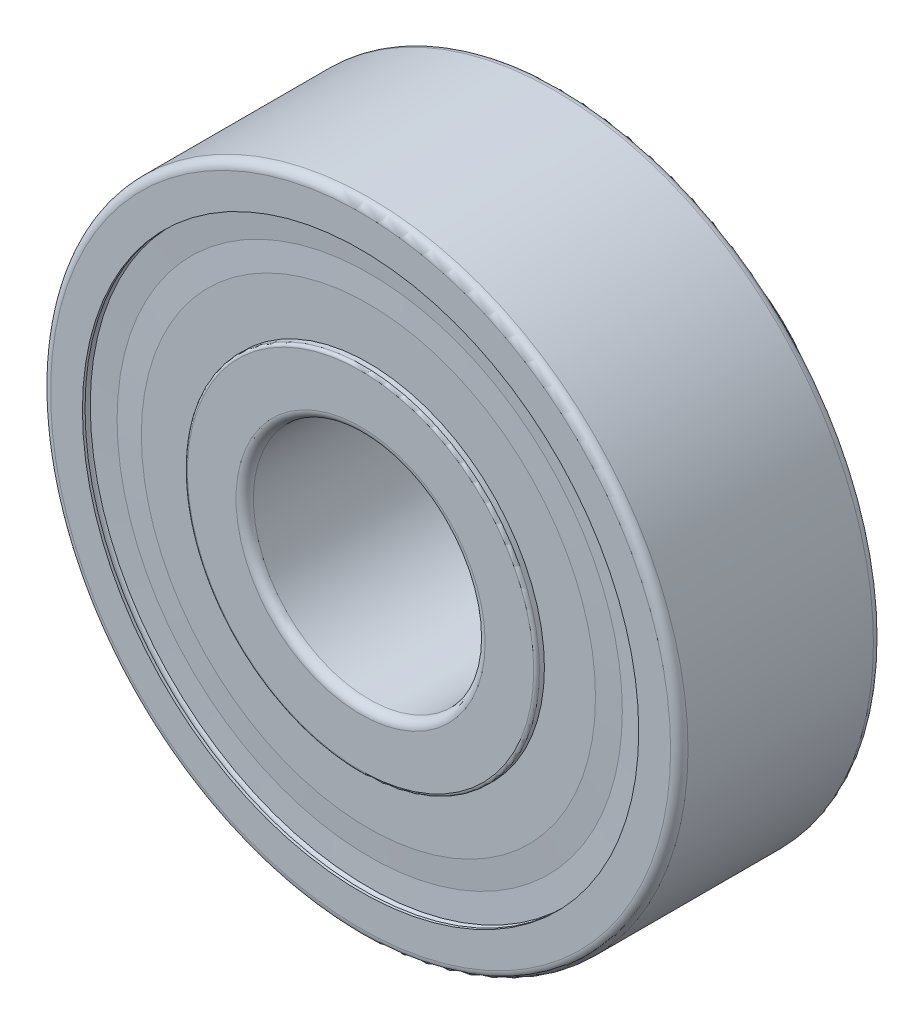
from build123d import *

# Parameters (mm, degrees)
BALL_PATTERN_COUNT              = 7
M3_SET_SCREW_HOLE_PATTERN_COUNT = 2
M3_SET_SCREW_HOLE_PATTERN_ANGLE = 90


with BuildPart() as part:
    # Sketch1 → Bearing Body (revolve)
    with BuildSketch(Plane(origin=(0, 0, 0), x_dir=(0, 0, -1), z_dir=(1, 0, 0))):
        with BuildLine():
            Line((-3.2, 4), (3.2, 4))
            Line((3.2, 4), (7.05, 4))
            ThreePointArc((7.05, 4), (7.262132034, 4.087867966), (7.35, 4.3))
            Line((7.35, 4.3), (7.35, 5.35))
            ThreePointArc((7.35, 5.35), (7.320710678, 5.420710678), (7.25, 5.45))
            Line((7.25, 5.45), (3.6, 5.45))
            Line((3.6, 5.45), (3.5, 5.55))
            Line((3.5, 5.55), (3.5, 5.975))
            ThreePointArc((3.5, 5.975), (3.470710678, 6.045710678), (3.4, 6.075))
            Line((3.4, 6.075), (3.23, 6.075))
            Line((3.23, 6.075), (3.23, 7.8375))
            Line((3.23, 7.8375), (3.185, 8.71875))
            Line((3.185, 8.71875), (3.23, 9.6))
            Line((3.23, 9.6), (3.14, 9.6))
            Line((3.14, 9.6), (3.05, 8.71875))
            Line((3.05, 8.71875), (3.05, 7.8375))
            Line((3.05, 7.8375), (3.14, 6.075))
            Line((3.14, 6.075), (1.520728526, 6.075))
            ThreePointArc((1.520728526, 6.075), (0, 5.3655), (-1.520728526, 6.075))
            Line((-1.520728526, 6.075), (-3.14, 6.075))
            Line((-3.14, 6.075), (-3.05, 7.8375))
            Line((-3.05, 7.8375), (-3.05, 8.71875))
            Line((-3.05, 8.71875), (-3.14, 9.6))
            Line((-3.14, 9.6), (-3.23, 9.6))
            Line((-3.23, 9.6), (-3.185, 8.71875))
            Line((-3.185, 8.71875), (-3.23, 7.8375))
            Line((-3.23, 7.8375), (-3.23, 6.075))
            Line((-3.23, 6.075), (-3.4, 6.075))
            ThreePointArc((-3.4, 6.075), (-3.470710678, 6.045710678), (-3.5, 5.975))
            Line((-3.5, 5.975), (-3.5, 4.3))
            ThreePointArc((-3.5, 4.3), (-3.412132034, 4.087867966), (-3.2, 4))
        make_face()
        with BuildLine():
            Line((-3.5, 9.6), (-3.5, 10.7))
            ThreePointArc((-3.5, 10.7), (-3.412132034, 10.912132034), (-3.2, 11))
            Line((-3.2, 11), (3.2, 11))
            ThreePointArc((3.2, 11), (3.412132034, 10.912132034), (3.5, 10.7))
            Line((3.5, 10.7), (3.5, 9.6))
            Line((3.5, 9.6), (3.41, 9.6))
            ThreePointArc((3.41, 9.6), (3.23, 9.78), (3.05, 9.6))
            Line((3.05, 9.6), (2.908938415, 8.8))
            Line((2.908938415, 8.8), (1.354894922, 8.8))
            ThreePointArc((1.354894922, 8.8), (0, 9.3345), (-1.354894922, 8.8))
            Line((-1.354894922, 8.8), (-2.908938415, 8.8))
            Line((-2.908938415, 8.8), (-3.05, 9.6))
            ThreePointArc((-3.05, 9.6), (-3.23, 9.78), (-3.41, 9.6))
            Line((-3.41, 9.6), (-3.5, 9.6))
        make_face()
    revolve(axis=Axis((0, 0, 3.5), (0, 0, -1)))

    # Sketch6 → M3 Set Screw Hole (revolve, cut)
    with BuildSketch(Plane(origin=(0, 5.45, -5.425), x_dir=(0, 0, 1), z_dir=(1, 0, 0))):
        Polygon((0, 0), (0, 8.251075774), (1.25, 7.5), (1.25, 0), align=None)
    m3_set_screw_hole = revolve(axis=Axis((0, 11.8, -5.425), (0, -1, 0)), mode=Mode.SUBTRACT)

    # M3 Set Screw Hole Pattern: M3 Set Screw Hole ×2 about axis
    m3_set_screw_hole_pattern_axis = Axis((0, 0, -7.05), (0, 0, -1))
    for i in range(1, M3_SET_SCREW_HOLE_PATTERN_COUNT):
        add(m3_set_screw_hole.rotate(m3_set_screw_hole_pattern_axis, i * M3_SET_SCREW_HOLE_PATTERN_ANGLE / (M3_SET_SCREW_HOLE_PATTERN_COUNT - 1)), mode=Mode.SUBTRACT)


with BuildPart() as body_2:
    # Sketch2 → Ball (revolve)
    with BuildSketch(Plane(origin=(0, 0, 0), x_dir=(0, 0, -1), z_dir=(1, 0, 0))):
        with BuildLine():
            Line((1.9845, 7.35), (-1.9845, 7.35))
            ThreePointArc((-1.9845, 7.35), (0, 5.3655), (1.9845, 7.35))
        make_face()
    revolve(axis=Axis((0, 7.35, -1.9845), (0, 0, 1)))


with BuildPart() as ball_pattern_1:
    # Ball Pattern: pattern copy
    add(body_2.part.rotate(Axis((0, 0, 0), (0, 0, 1)), 1 * 360 / BALL_PATTERN_COUNT))


with BuildPart() as ball_pattern_2:
    # Ball Pattern: pattern copy
    add(body_2.part.rotate(Axis((0, 0, 0), (0, 0, 1)), 2 * 360 / BALL_PATTERN_COUNT))


with BuildPart() as ball_pattern_3:
    # Ball Pattern: pattern copy
    add(body_2.part.rotate(Axis((0, 0, 0), (0, 0, 1)), 3 * 360 / BALL_PATTERN_COUNT))


with BuildPart() as ball_pattern_4:
    # Ball Pattern: pattern copy
    add(body_2.part.rotate(Axis((0, 0, 0), (0, 0, 1)), 4 * 360 / BALL_PATTERN_COUNT))


with BuildPart() as ball_pattern_5:
    # Ball Pattern: pattern copy
    add(body_2.part.rotate(Axis((0, 0, 0), (0, 0, 1)), 5 * 360 / BALL_PATTERN_COUNT))


with BuildPart() as ball_pattern_6:
    # Ball Pattern: pattern copy
    add(body_2.part.rotate(Axis((0, 0, 0), (0, 0, 1)), 6 * 360 / BALL_PATTERN_COUNT))


solid = Compound([part.part, body_2.part, ball_pattern_1.part, ball_pattern_2.part, ball_pattern_3.part, ball_pattern_4.part, ball_pattern_5.part, ball_pattern_6.part])
